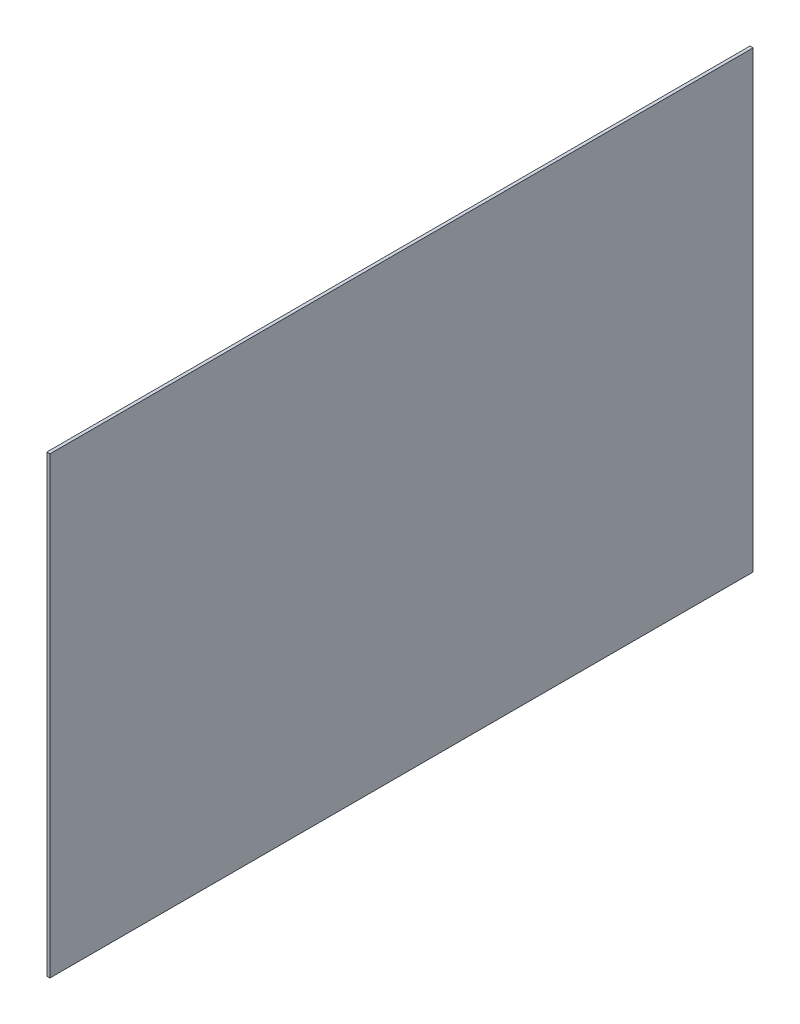
from build123d import *

# Parameters (mm, degrees)
SKETCH1_W           = 900
SKETCH1_H           = 581
BOSS_EXTRUDE1_DEPTH = 4


with BuildPart() as part:
    # Sketch1 → Boss-Extrude1 (new body)
    with BuildSketch(Plane(origin=(0, 0, 0), x_dir=(0, 0, -1), z_dir=(1, 0, 0))):
        with Locations((340.647637939, 97.095671182)):
            Rectangle(SKETCH1_W, SKETCH1_H)
    extrude(amount=BOSS_EXTRUDE1_DEPTH)


solid = part.part
